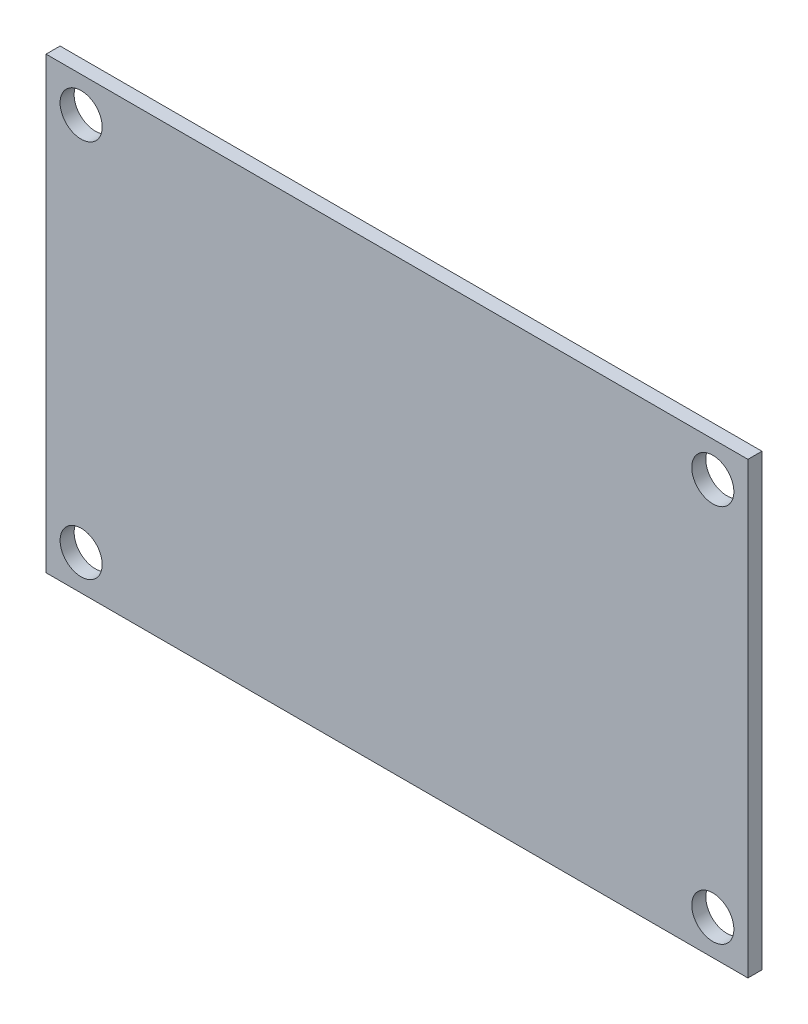
from build123d import *

# Parameters (mm, degrees)
ESQUISSE1_W             = 50
ESQUISSE1_H             = 32
BOSS_EXTRU_1_DEPTH      = 1
ESQUISSE2_R             = 1.5
ENL_V_MAT_EXTRU_1_DEPTH = 2


with BuildPart() as part:
    # Esquisse1 → Boss.-Extru.1 (new body)
    with BuildSketch(Plane.XY):
        with Locations((25, 16)):
            Rectangle(ESQUISSE1_W, ESQUISSE1_H)
    extrude(amount=BOSS_EXTRU_1_DEPTH)

    # Esquisse2 → Enlèv. mat.-Extru.1 (cut, through all)
    with BuildSketch(Plane(origin=(0, 0, 0), x_dir=(-1, 0, 0), z_dir=(0, 0, -1))):
        with Locations((-2.5, 29.5)):
            Circle(ESQUISSE2_R)
        with Locations((-2.5, 2.5)):
            Circle(ESQUISSE2_R)
        with Locations((-47.5, 2.5)):
            Circle(ESQUISSE2_R)
        with Locations((-47.5, 29.5)):
            Circle(ESQUISSE2_R)
    extrude(amount=-ENL_V_MAT_EXTRU_1_DEPTH, mode=Mode.SUBTRACT)


solid = part.part
